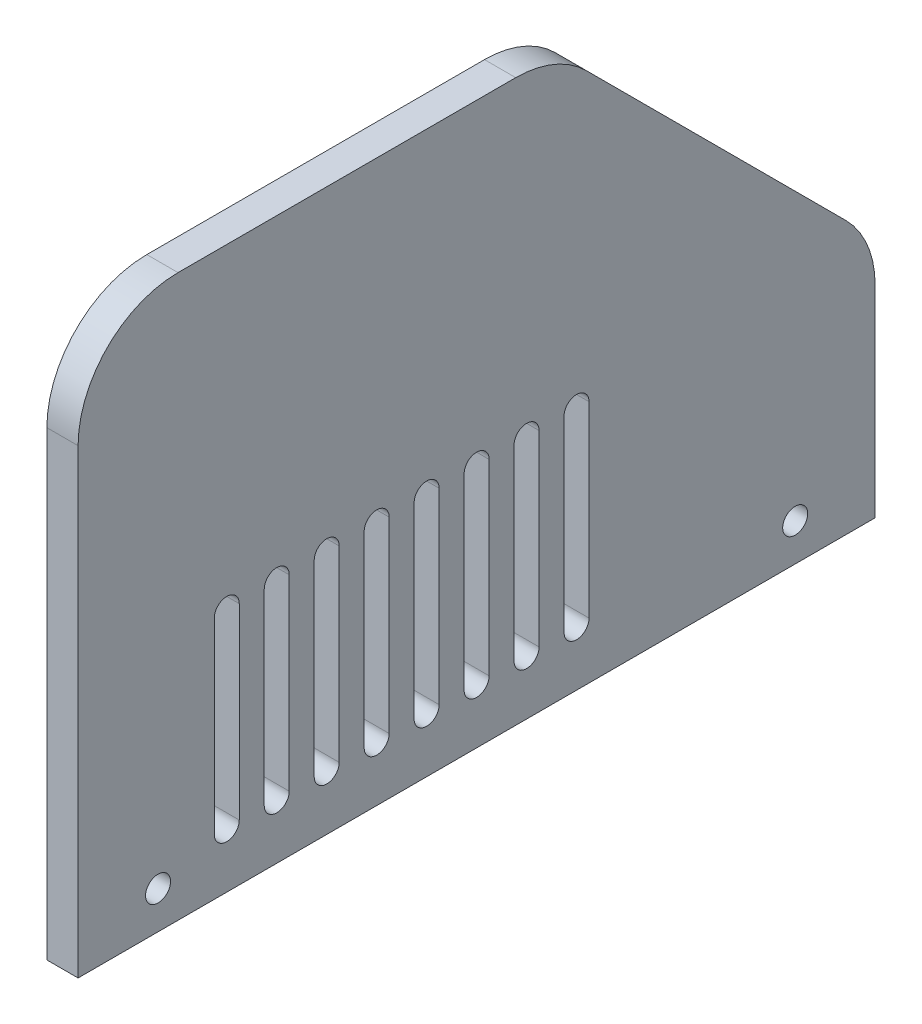
from build123d import *

# Parameters (mm, degrees)
SKETCH1_R           = 1.27
BOSS_EXTRUDE1_DEPTH = 3.175
FILLET1_R           = 10.16


with BuildPart() as part:
    # Sketch1 → Boss-Extrude1 (new body)
    with BuildSketch(Plane(origin=(0, 0, 0), x_dir=(0, 0, -1), z_dir=(1, 0, 0))):
        Polygon((0, 0), (81.026, 0), (81.026, 24.694077964), (48.697077964, 57.023), (0, 57.023), align=None)
        with Locations((8.128, 3.81)):
            Circle(SKETCH1_R, mode=Mode.SUBTRACT)
        with Locations((72.898, 3.81)):
            Circle(SKETCH1_R, mode=Mode.SUBTRACT)
        with BuildLine():
            Line((51.943, 24.765), (51.943, 5.715))
            ThreePointArc((51.943, 5.715), (50.673, 4.445), (49.403, 5.715))
            Line((49.403, 5.715), (49.403, 24.765))
            ThreePointArc((49.403, 24.765), (50.673, 26.035), (51.943, 24.765))
        make_face(mode=Mode.SUBTRACT)
        with BuildLine():
            Line((46.863, 24.765), (46.863, 5.715))
            ThreePointArc((46.863, 5.715), (45.593, 4.445), (44.323, 5.715))
            Line((44.323, 5.715), (44.323, 24.765))
            ThreePointArc((44.323, 24.765), (45.593, 26.035), (46.863, 24.765))
        make_face(mode=Mode.SUBTRACT)
        with BuildLine():
            Line((16.383, 24.765), (16.383, 5.715))
            ThreePointArc((16.383, 5.715), (15.113, 4.445), (13.843, 5.715))
            Line((13.843, 5.715), (13.843, 24.765))
            ThreePointArc((13.843, 24.765), (15.113, 26.035), (16.383, 24.765))
        make_face(mode=Mode.SUBTRACT)
        with BuildLine():
            Line((41.783, 24.765), (41.783, 5.715))
            ThreePointArc((41.783, 5.715), (40.513, 4.445), (39.243, 5.715))
            Line((39.243, 5.715), (39.243, 24.765))
            ThreePointArc((39.243, 24.765), (40.513, 26.035), (41.783, 24.765))
        make_face(mode=Mode.SUBTRACT)
        with BuildLine():
            Line((36.703, 24.765), (36.703, 5.715))
            ThreePointArc((36.703, 5.715), (35.433, 4.445), (34.163, 5.715))
            Line((34.163, 5.715), (34.163, 24.765))
            ThreePointArc((34.163, 24.765), (35.433, 26.035), (36.703, 24.765))
        make_face(mode=Mode.SUBTRACT)
        with BuildLine():
            Line((31.623, 24.765), (31.623, 5.715))
            ThreePointArc((31.623, 5.715), (30.353, 4.445), (29.083, 5.715))
            Line((29.083, 5.715), (29.083, 24.765))
            ThreePointArc((29.083, 24.765), (30.353, 26.035), (31.623, 24.765))
        make_face(mode=Mode.SUBTRACT)
        with BuildLine():
            Line((26.543, 24.765), (26.543, 5.715))
            ThreePointArc((26.543, 5.715), (25.273, 4.445), (24.003, 5.715))
            Line((24.003, 5.715), (24.003, 24.765))
            ThreePointArc((24.003, 24.765), (25.273, 26.035), (26.543, 24.765))
        make_face(mode=Mode.SUBTRACT)
        with BuildLine():
            Line((21.463, 24.765), (21.463, 5.715))
            ThreePointArc((21.463, 5.715), (20.193, 4.445), (18.923, 5.715))
            Line((18.923, 5.715), (18.923, 24.765))
            ThreePointArc((18.923, 24.765), (20.193, 26.035), (21.463, 24.765))
        make_face(mode=Mode.SUBTRACT)
    extrude(amount=BOSS_EXTRUDE1_DEPTH)

    # Fillet1
    fillet1_edges = [part.edges().sort_by_distance(p)[0] for p in [
        (1.5875, 57.023, -48.697077964),
        (1.5875, 24.694077964, -81.026),
        (1.5875, 57.023, 0),
    ]]
    fillet(fillet1_edges, radius=FILLET1_R)


solid = part.part
